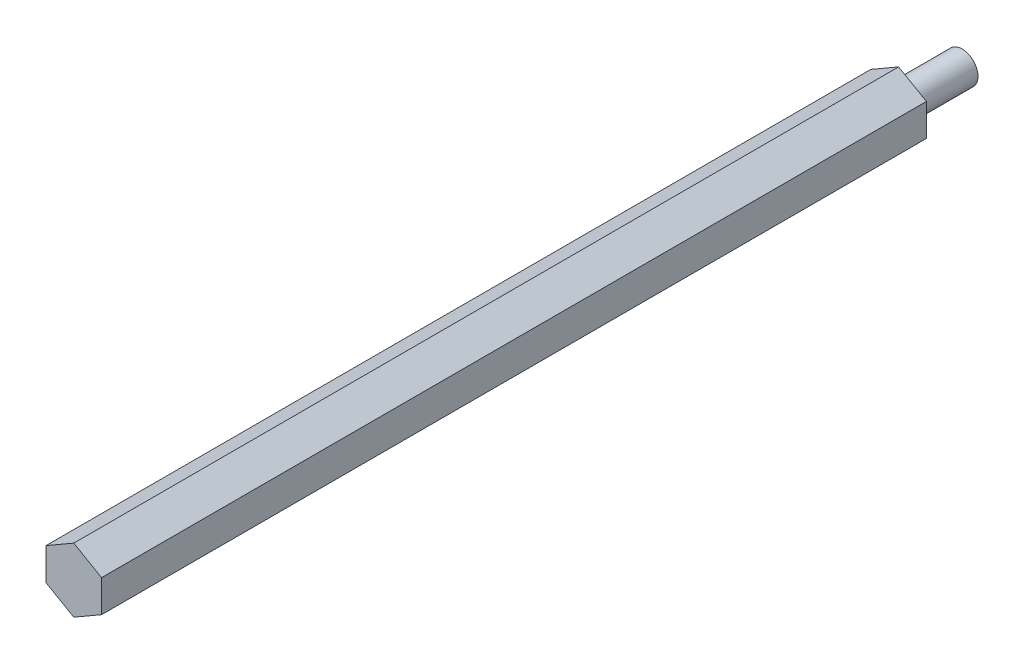
from build123d import *

# Parameters (mm, degrees)
BOSS_EXTRUDE2_DEPTH      = 82.5
BOSS_EXTRUDE2_DEPTH_BACK = 82.5
SKETCH4_R                = 3.175
BOSS_EXTRUDE3_DEPTH      = 12.7


with BuildPart() as part:
    # Sketch3 → Boss-Extrude2 (new body, two sides)
    with BuildSketch(Plane.XY) as boss_extrude2_sk:
        Polygon((-5.55625, -3.207902433), (0, -6.415804866), (5.55625, -3.207902433), (5.55625, 3.207902433), (0, 6.415804866), (-5.55625, 3.207902433), align=None)
    extrude(amount=BOSS_EXTRUDE2_DEPTH)
    extrude(boss_extrude2_sk.sketch, amount=-BOSS_EXTRUDE2_DEPTH_BACK)

    # Sketch4 → Boss-Extrude3 (add)
    with BuildSketch(Plane.XY.offset(-82.5)):
        Circle(SKETCH4_R)
    extrude(amount=-BOSS_EXTRUDE3_DEPTH)


solid = part.part
